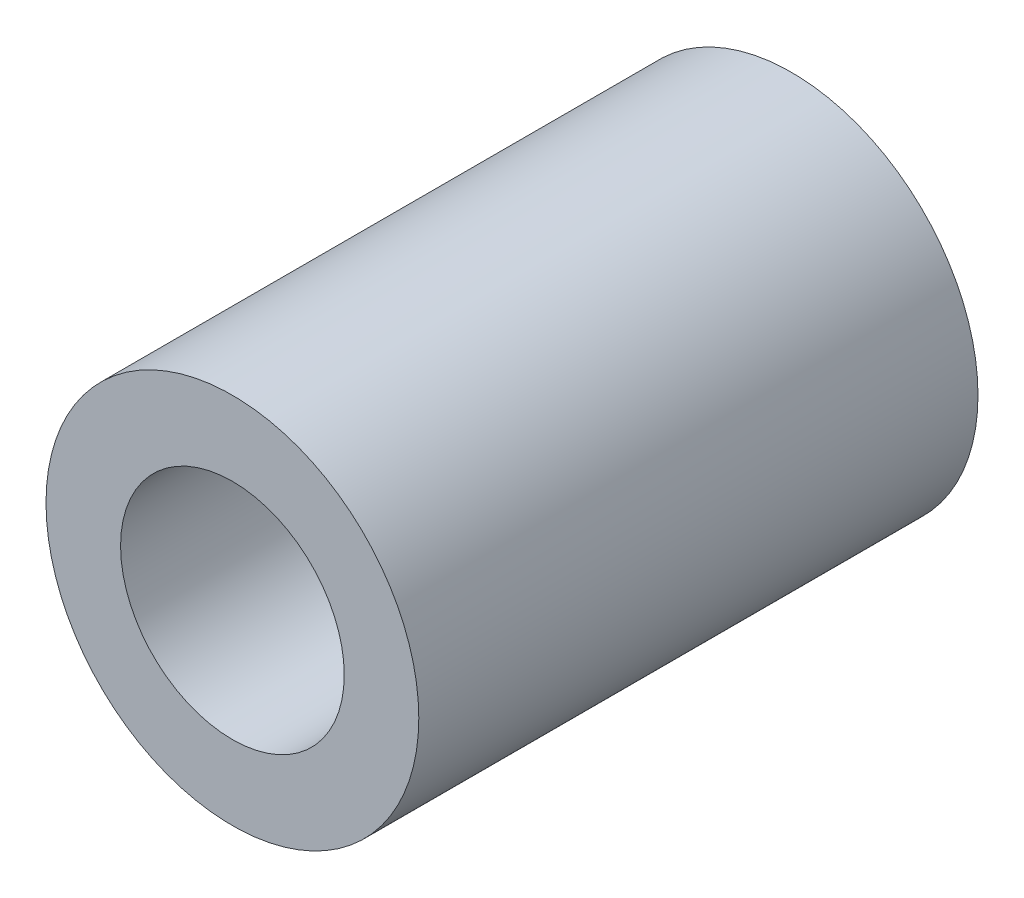
from build123d import *

# Parameters (mm, degrees)
ESQUISSE1_R        = 2
ESQUISSE1_R_2      = 1.2
BOSS_EXTRU_1_DEPTH = 6


with BuildPart() as part:
    # Esquisse1 → Boss.-Extru.1 (new body)
    with BuildSketch(Plane.XY):
        Circle(ESQUISSE1_R)
        Circle(ESQUISSE1_R_2, mode=Mode.SUBTRACT)
    extrude(amount=BOSS_EXTRU_1_DEPTH)


solid = part.part
